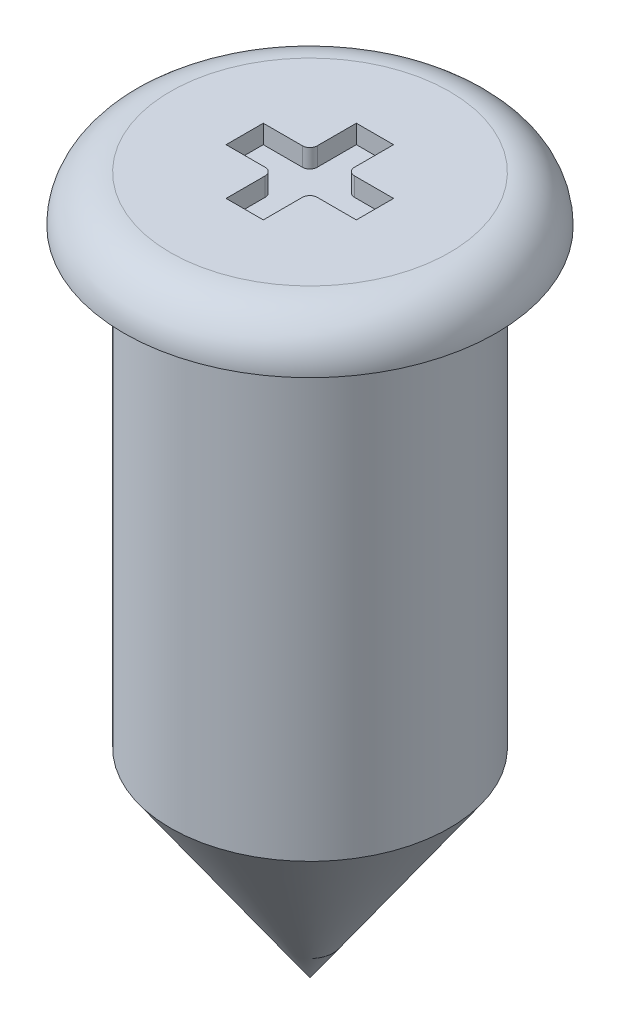
from build123d import *

# Parameters (mm, degrees)
CUT_EXTRUDE1_DEPTH = 0.1


with BuildPart() as part:
    # Sketch1 → Revolve1 (revolve)
    with BuildSketch(Plane.XY):
        with BuildLine():
            Line((0, -10.655976488), (0, -14.405976488))
            Line((0, -14.405976488), (0.75, -13.333296431))
            Line((0.75, -13.333296431), (0.75, -10.905976488))
            Line((0.75, -10.905976488), (1, -10.905976488))
            ThreePointArc((1, -10.905976488), (0.926776695, -10.729199793), (0.75, -10.655976488))
            Line((0.75, -10.655976488), (0, -10.655976488))
        make_face()
    revolve(axis=Axis((0, -10.655976488, 0), (0, -1, 0)))

    # Sketch2 → Cut-Extrude1 (cut)
    with BuildSketch(Plane(origin=(0, -10.655976488, 0), x_dir=(1, 0, 0), z_dir=(0, 1, 0))):
        with BuildLine():
            Line((-0.102700854, 0.351707003), (0.097299146, 0.351707003))
            Line((0.097299146, 0.351707003), (0.097299146, 0.141707003))
            ThreePointArc((0.097299146, 0.141707003), (0.109014874, 0.113422731), (0.137299146, 0.101707003))
            Line((0.137299146, 0.101707003), (0.347299146, 0.101707003))
            Line((0.347299146, 0.101707003), (0.347299146, -0.098292997))
            Line((0.347299146, -0.098292997), (0.137299146, -0.098292997))
            ThreePointArc((0.137299146, -0.098292997), (0.109014874, -0.110008726), (0.097299146, -0.138292997))
            Line((0.097299146, -0.138292997), (0.097299146, -0.348292997))
            Line((0.097299146, -0.348292997), (-0.102700854, -0.348292997))
            Line((-0.102700854, -0.348292997), (-0.102700854, -0.138292997))
            ThreePointArc((-0.102700854, -0.138292997), (-0.114416583, -0.110008726), (-0.142700854, -0.098292997))
            Line((-0.142700854, -0.098292997), (-0.352700854, -0.098292997))
            Line((-0.352700854, -0.098292997), (-0.352700854, 0.101707003))
            Line((-0.352700854, 0.101707003), (-0.142700854, 0.101707003))
            ThreePointArc((-0.142700854, 0.101707003), (-0.114416583, 0.113422731), (-0.102700854, 0.141707003))
            Line((-0.102700854, 0.141707003), (-0.102700854, 0.351707003))
        make_face()
    extrude(amount=-CUT_EXTRUDE1_DEPTH, mode=Mode.SUBTRACT)


solid = part.part
